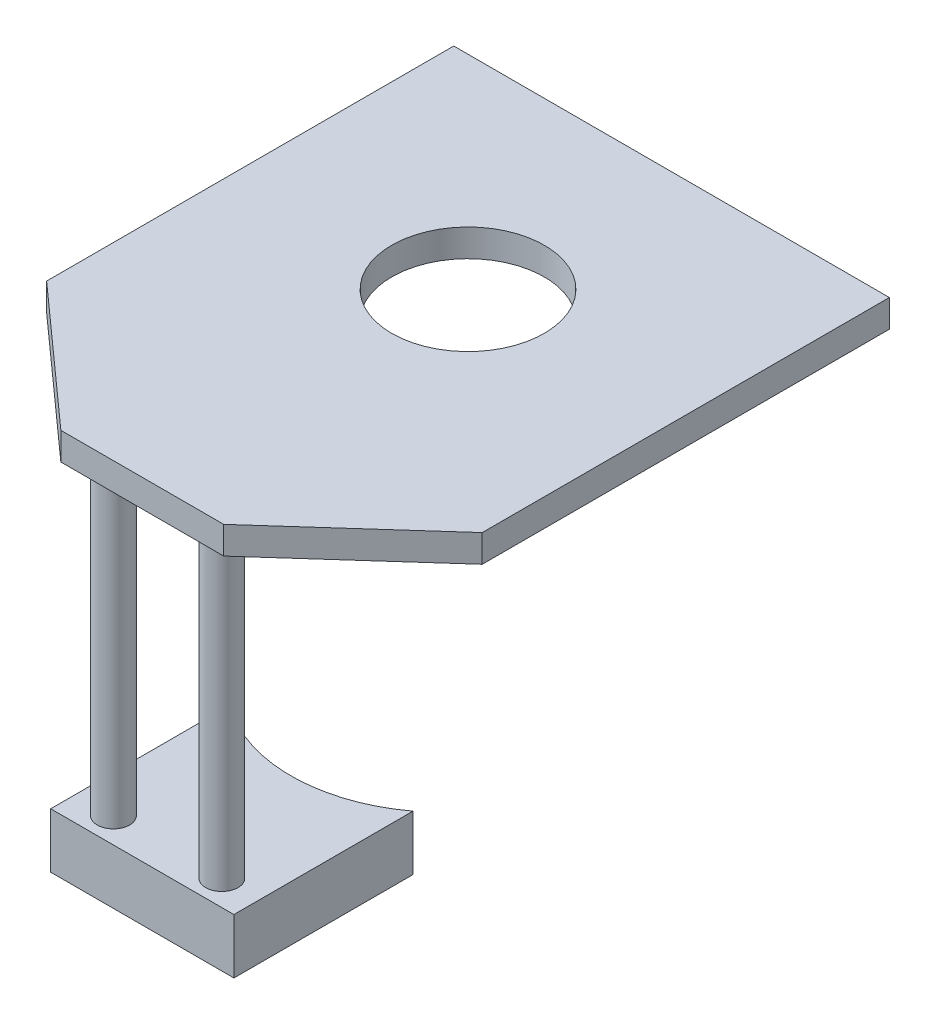
from build123d import *

# Parameters (mm, degrees)
SKETCH2_R           = 37.5
BOSS_EXTRUDE1_DEPTH = 6.75
SKETCH3_R           = 7.95
BOSS_EXTRUDE2_DEPTH = 150
BOSS_EXTRUDE3_DEPTH = 27


with BuildPart() as part:
    # Sketch2 → Boss-Extrude1 (new body, symmetric)
    with BuildSketch(Plane(origin=(0, 0, 0), x_dir=(1, 0, 0), z_dir=(0, 1, 0))):
        Polygon((-107, -100), (-40, -160), (40, -160), (107, -100), (107, 100), (-107, 100), align=None)
        Circle(SKETCH2_R, mode=Mode.SUBTRACT)
    extrude(amount=BOSS_EXTRUDE1_DEPTH, both=True)

    # Sketch3 → Boss-Extrude2 (add)
    with BuildSketch(Plane.XZ.offset(6.75)):
        with Locations((26.625, 147.55)):
            Circle(SKETCH3_R)
        with Locations((-26.625, 147.55)):
            Circle(SKETCH3_R)
    extrude(amount=BOSS_EXTRUDE2_DEPTH)

    # Sketch4 → Boss-Extrude3 (add)
    with BuildSketch(Plane.XZ.offset(156.75)):
        with BuildLine():
            Line((-45, 72), (-45, 160))
            Line((-45, 160), (45, 160))
            Line((45, 160), (45, 72))
            ThreePointArc((45, 72), (0, 87), (-45, 72))
        make_face()
    extrude(amount=BOSS_EXTRUDE3_DEPTH)


solid = part.part
